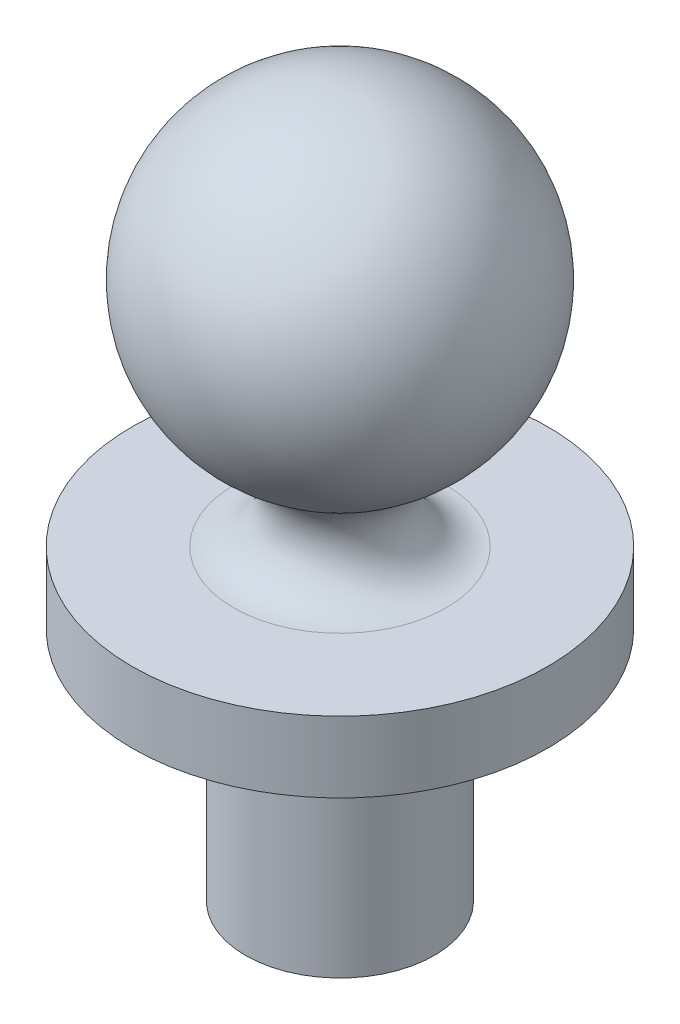
from build123d import *


with BuildPart() as part:
    # Sketch1 → Revolve1 (revolve)
    with BuildSketch(Plane.XY):
        with BuildLine():
            ThreePointArc((-0.875, -1.515544457), (-0.642037087, -2.077966681), (-1.125, -2.448557159))
            Line((-1.125, -2.448557159), (-2.2, -2.448557159))
            Line((-2.2, -2.448557159), (-2.2, -3.198557159))
            Line((-2.2, -3.198557159), (-1, -3.198557159))
            Line((-1, -3.198557159), (-1, -5.698557159))
            Line((-1, -5.698557159), (0, -5.698557159))
            Line((0, -5.698557159), (0, -1.75))
            ThreePointArc((0, -1.75), (-0.452933329, -1.690370196), (-0.875, -1.515544457))
        make_face()
        with BuildLine():
            ThreePointArc((0, -1.75), (-1.75, 0), (0, 1.75))
            Line((0, 1.75), (0, -1.75))
        make_face()
    revolve(axis=Axis((0, 40.420109298, 0), (0, -1, 0)))


solid = part.part
